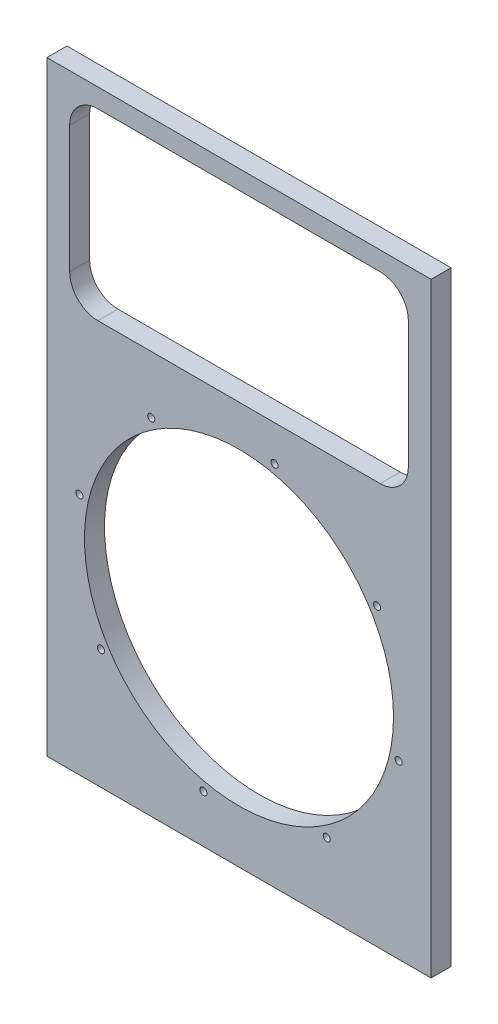
from build123d import *

# Parameters (mm, degrees)
SKETCH1_W           = 345.7
SKETCH1_H           = 544.6
BOSS_EXTRUDE1_DEPTH = 18
SKETCH2_W           = 266.7
SKETCH2_H           = 127
CUT_EXTRUDE1_DEPTH  = 19
SKETCH3_R           = 139.065
CUT_EXTRUDE2_DEPTH  = 19
SKETCH4_R           = 3.175
CUT_EXTRUDE3_DEPTH  = 19
CUT_EXTRUDE4_DEPTH  = 19


with BuildPart() as part:
    # Sketch1 → Boss-Extrude1 (new body)
    with BuildSketch(Plane.XY):
        with Locations((172.85, 272.3)):
            Rectangle(SKETCH1_W, SKETCH1_H)
    extrude(amount=BOSS_EXTRUDE1_DEPTH)

    # Sketch2 → Cut-Extrude1 (cut, through all)
    with BuildSketch(Plane.XY.offset(18)):
        with Locations((172.85, 445)):
            Rectangle(SKETCH2_W, SKETCH2_H)
    extrude(amount=-CUT_EXTRUDE1_DEPTH, mode=Mode.SUBTRACT)

    # Sketch3 → Cut-Extrude2 (cut, through all)
    with BuildSketch(Plane.XY.offset(18)):
        with Locations((172.85, 186.690965799)):
            Circle(SKETCH3_R)
    extrude(amount=-CUT_EXTRUDE2_DEPTH, mode=Mode.SUBTRACT)

    # Sketch4 → Cut-Extrude3 (cut, through all)
    with BuildSketch(Plane.XY.offset(18)):
        with Locations((204.842157428, 330.365184475)):
            Circle(SKETCH4_R)
        with Locations((297.06488577, 265.662108644)):
            Circle(SKETCH4_R)
        with Locations((316.524218676, 154.698808371)):
            Circle(SKETCH4_R)
        with Locations((251.821142845, 62.476080029)):
            Circle(SKETCH4_R)
        with Locations((140.857842572, 43.016747123)):
            Circle(SKETCH4_R)
        with Locations((48.63511423, 107.719822954)):
            Circle(SKETCH4_R)
        with Locations((29.175781324, 218.683123227)):
            Circle(SKETCH4_R)
        with Locations((93.878857155, 310.905851569)):
            Circle(SKETCH4_R)
    extrude(amount=-CUT_EXTRUDE3_DEPTH, mode=Mode.SUBTRACT)

    # Sketch6 → Cut-Extrude4 (cut, through all)
    with BuildSketch(Plane.XY.offset(18)):
        with BuildLine():
            Line((45.85, 362.45), (299.85, 362.45))
            ThreePointArc((299.85, 362.45), (317.810512242, 369.889487758), (325.25, 387.85))
            Line((325.25, 387.85), (325.25, 502.15))
            ThreePointArc((325.25, 502.15), (317.810512242, 520.110512242), (299.85, 527.55))
            Line((299.85, 527.55), (45.85, 527.55))
            ThreePointArc((45.85, 527.55), (27.889487758, 520.110512242), (20.45, 502.15))
            Line((20.45, 502.15), (20.45, 387.85))
            ThreePointArc((20.45, 387.85), (27.889487758, 369.889487758), (45.85, 362.45))
        make_face()
    extrude(amount=-CUT_EXTRUDE4_DEPTH, mode=Mode.SUBTRACT)


solid = part.part
